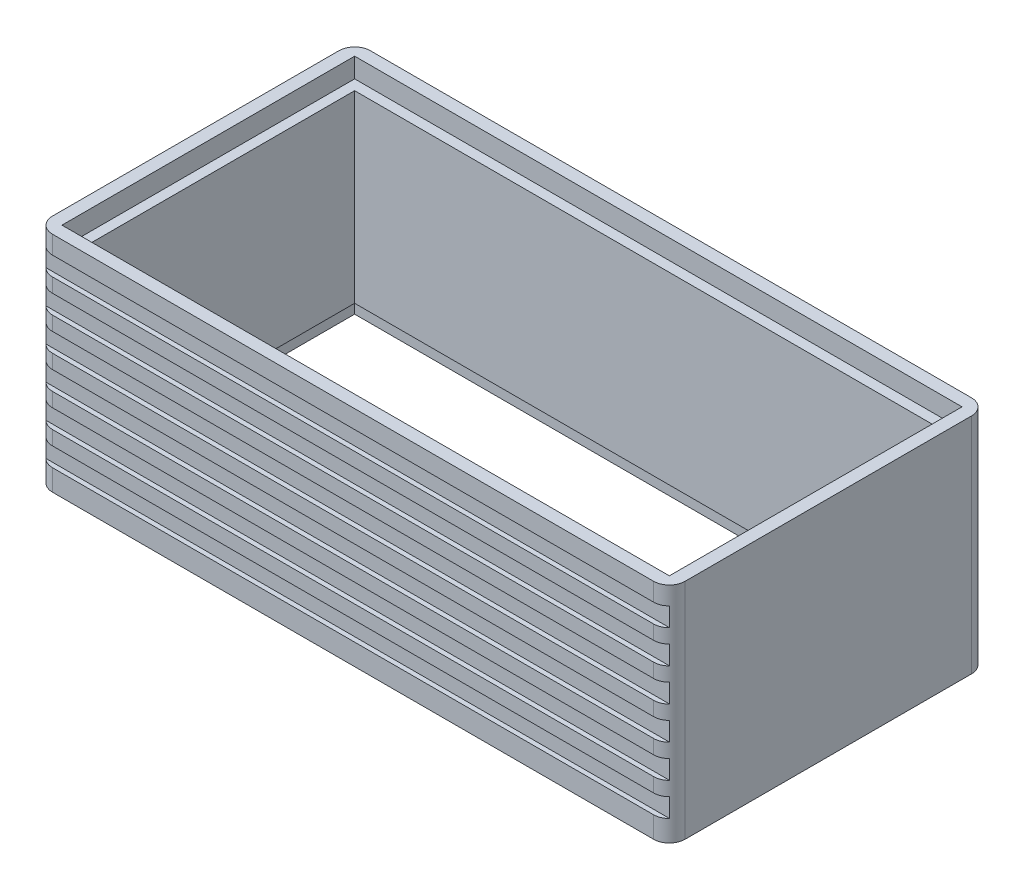
from build123d import *

# Parameters (mm, degrees)
SKETCH1_W                = 40.2
SKETCH1_H                = 20.2
BOSS_EXTRUDE1_DEPTH      = 7.1
BOSS_EXTRUDE1_DEPTH_BACK = 7.1
FILLET1_R                = 1
SKETCH2_W                = 38.6
SKETCH2_H                = 18.6
CUT_EXTRUDE1_DEPTH       = 1.25
SKETCH3_W                = 37.3
SKETCH3_H                = 17.3
CUT_EXTRUDE2_DEPTH       = 13.95
SKETCH4_W                = 0.3
SKETCH4_H                = 1.2
CUT_EXTRUDE3_DEPTH       = 41.2
LPATTERN1_COUNT          = 6
LPATTERN1_PITCH          = 2.1
MIRROR2_COPY_1_SKETCH_W  = 0.3
MIRROR2_COPY_1_SKETCH_H  = 1.2
MIRROR2_COPY_1_DEPTH     = 41.2
MIRROR2_COPY_2_SKETCH_W  = 0.3
MIRROR2_COPY_2_SKETCH_H  = 1.2
MIRROR2_COPY_2_DEPTH     = 41.2
MIRROR2_COPY_3_SKETCH_W  = 0.3
MIRROR2_COPY_3_SKETCH_H  = 1.2
MIRROR2_COPY_3_DEPTH     = 41.2
MIRROR2_COPY_4_SKETCH_W  = 0.3
MIRROR2_COPY_4_SKETCH_H  = 1.2
MIRROR2_COPY_4_DEPTH     = 41.2
MIRROR2_COPY_5_SKETCH_W  = 0.3
MIRROR2_COPY_5_SKETCH_H  = 1.2
MIRROR2_COPY_5_DEPTH     = 41.2


with BuildPart() as part:
    # Sketch1 → Boss-Extrude1 (new body, two sides)
    with BuildSketch(Plane(origin=(0, 0, 0), x_dir=(1, 0, 0), z_dir=(0, 1, 0))) as boss_extrude1_sk:
        Rectangle(SKETCH1_W, SKETCH1_H)
    extrude(amount=BOSS_EXTRUDE1_DEPTH)
    extrude(boss_extrude1_sk.sketch, amount=-BOSS_EXTRUDE1_DEPTH_BACK)

    # Fillet1
    fillet1_edges = [part.edges().sort_by_distance(p)[0] for p in [
        (-20.1, 0, -10.1),
        (20.1, 0, -10.1),
        (20.1, 0, 10.1),
        (-20.1, 0, 10.1),
    ]]
    fillet(fillet1_edges, radius=FILLET1_R)

    # Sketch2 → Cut-Extrude1 (cut)
    with BuildSketch(Plane(origin=(0, 7.1, 0), x_dir=(1, 0, 0), z_dir=(0, 1, 0))):
        Rectangle(SKETCH2_W, SKETCH2_H)
    cut_extrude1 = extrude(amount=-CUT_EXTRUDE1_DEPTH, mode=Mode.SUBTRACT)

    # Sketch3 → Cut-Extrude2 (cut, through all)
    with BuildSketch(Plane(origin=(0, 5.85, 0), x_dir=(1, 0, 0), z_dir=(0, 1, 0))):
        Rectangle(SKETCH3_W, SKETCH3_H)
    extrude(amount=-CUT_EXTRUDE2_DEPTH, mode=Mode.SUBTRACT)

    # Mirror1: Cut-Extrude1 across plane
    add(cut_extrude1.mirror(Plane.ZX), mode=Mode.SUBTRACT)

    # Sketch4 → Cut-Extrude3 (cut, through all)
    with BuildSketch(Plane(origin=(20.1, 0, 0), x_dir=(0, 0, -1), z_dir=(1, 0, 0))):
        with Locations((-9.95, 5.35)):
            Rectangle(SKETCH4_W, SKETCH4_H)
    cut_extrude3 = extrude(amount=-CUT_EXTRUDE3_DEPTH, mode=Mode.SUBTRACT)

    # LPattern1: Cut-Extrude3 ×6
    with Locations(*[(0, -i * LPATTERN1_PITCH, 0) for i in range(1, LPATTERN1_COUNT)]):
        add(cut_extrude3, mode=Mode.SUBTRACT)

    # Mirror2: Cut-Extrude3 across plane
    add(cut_extrude3.mirror(Plane.XY), mode=Mode.SUBTRACT)

    # Mirror2 copy 1 sketch → Mirror2 copy 1 (cut, through all)
    with BuildSketch(Plane(origin=(20.1, -2.1, 0), x_dir=(0, 0, 1), z_dir=(1, 0, 0))):
        with Locations((-9.95, -5.35)):
            Rectangle(MIRROR2_COPY_1_SKETCH_W, MIRROR2_COPY_1_SKETCH_H)
    extrude(amount=-MIRROR2_COPY_1_DEPTH, mode=Mode.SUBTRACT)

    # Mirror2 copy 2 sketch → Mirror2 copy 2 (cut, through all)
    with BuildSketch(Plane(origin=(20.1, -4.2, 0), x_dir=(0, 0, 1), z_dir=(1, 0, 0))):
        with Locations((-9.95, -5.35)):
            Rectangle(MIRROR2_COPY_2_SKETCH_W, MIRROR2_COPY_2_SKETCH_H)
    extrude(amount=-MIRROR2_COPY_2_DEPTH, mode=Mode.SUBTRACT)

    # Mirror2 copy 3 sketch → Mirror2 copy 3 (cut, through all)
    with BuildSketch(Plane(origin=(20.1, -6.3, 0), x_dir=(0, 0, 1), z_dir=(1, 0, 0))):
        with Locations((-9.95, -5.35)):
            Rectangle(MIRROR2_COPY_3_SKETCH_W, MIRROR2_COPY_3_SKETCH_H)
    extrude(amount=-MIRROR2_COPY_3_DEPTH, mode=Mode.SUBTRACT)

    # Mirror2 copy 4 sketch → Mirror2 copy 4 (cut, through all)
    with BuildSketch(Plane(origin=(20.1, -8.4, 0), x_dir=(0, 0, 1), z_dir=(1, 0, 0))):
        with Locations((-9.95, -5.35)):
            Rectangle(MIRROR2_COPY_4_SKETCH_W, MIRROR2_COPY_4_SKETCH_H)
    extrude(amount=-MIRROR2_COPY_4_DEPTH, mode=Mode.SUBTRACT)

    # Mirror2 copy 5 sketch → Mirror2 copy 5 (cut, through all)
    with BuildSketch(Plane(origin=(20.1, -10.5, 0), x_dir=(0, 0, 1), z_dir=(1, 0, 0))):
        with Locations((-9.95, -5.35)):
            Rectangle(MIRROR2_COPY_5_SKETCH_W, MIRROR2_COPY_5_SKETCH_H)
    extrude(amount=-MIRROR2_COPY_5_DEPTH, mode=Mode.SUBTRACT)


solid = part.part
